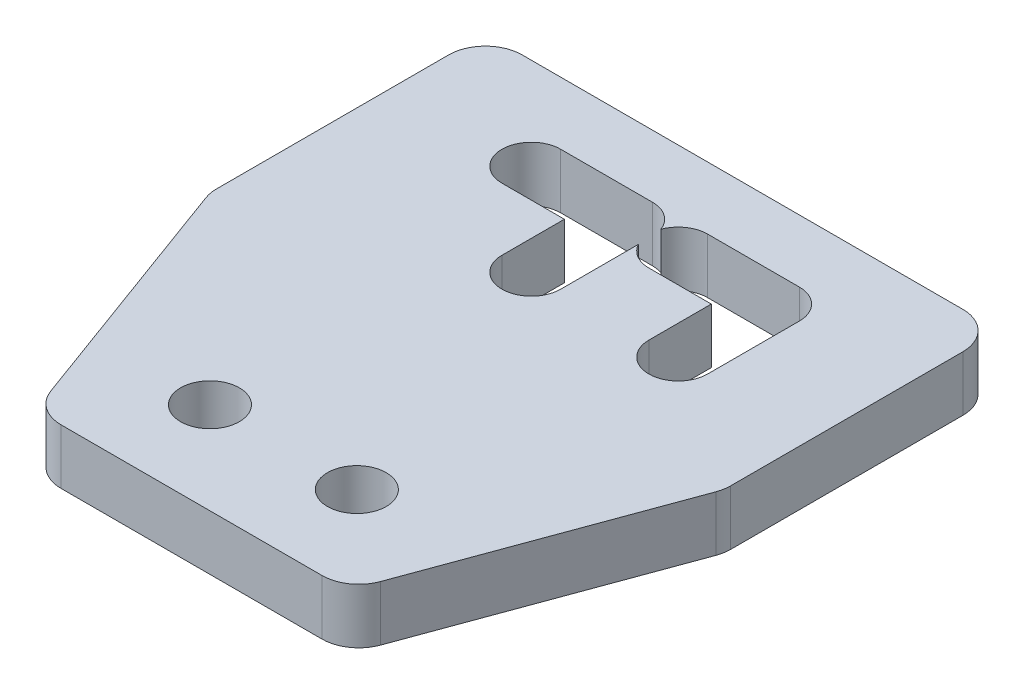
from build123d import *

# Parameters (mm, degrees)
SKETCH1_W           = 28
SKETCH1_H           = 30
BOSS_EXTRUDE1_DEPTH = 3
SKETCH2_R           = 1.6
CUT_EXTRUDE1_DEPTH  = 4
FILLET1_R           = 2


with BuildPart() as part:
    # Sketch1 → Boss-Extrude1 (new body)
    with BuildSketch(Plane(origin=(0, 0, 0), x_dir=(1, 0, 0), z_dir=(0, 1, 0))):
        Rectangle(SKETCH1_W, SKETCH1_H)
        with BuildLine():
            ThreePointArc((1.5, 8.4), (0.687397597, 8.621712173), (0.1, 9.225403331))
            Line((0.1, 9.225403331), (0.1, 5))
            ThreePointArc((0.1, 5), (-1.5, 3.4), (-3.1, 5))
            Line((-3.1, 5), (-3.1, 8.4))
            Line((-3.1, 8.4), (-6.5, 8.4))
            ThreePointArc((-6.5, 8.4), (-8.1, 10), (-6.5, 11.6))
            Line((-6.5, 11.6), (-1.5, 11.6))
            ThreePointArc((-1.5, 11.6), (-0.586447127, 11.313552873), (0, 10.556776436))
            ThreePointArc((0, 10.556776436), (0.586447127, 11.313552873), (1.5, 11.6))
            Line((1.5, 11.6), (6.5, 11.6))
            ThreePointArc((6.5, 11.6), (7.63137085, 11.13137085), (8.1, 10))
            Line((8.1, 10), (8.1, 5))
            ThreePointArc((8.1, 5), (6.5, 3.4), (4.9, 5))
            Line((4.9, 5), (4.9, 8.4))
            Line((4.9, 8.4), (1.5, 8.4))
        make_face(mode=Mode.SUBTRACT)
    extrude(amount=BOSS_EXTRUDE1_DEPTH)

    # Sketch2 → Cut-Extrude1 (cut, through all)
    with BuildSketch(Plane(origin=(0, 3, 0), x_dir=(1, 0, 0), z_dir=(0, 1, 0))):
        with Locations((-4, -10)):
            Circle(SKETCH2_R)
        with Locations((4, -10)):
            Circle(SKETCH2_R)
        Polygon((14, 0), (8.5, -15), (14, -15), align=None)
        Polygon((-8.5, -15), (-14, -15), (-14, 0), align=None)
    extrude(amount=-CUT_EXTRUDE1_DEPTH, mode=Mode.SUBTRACT)

    # Fillet1
    fillet1_edges = [part.edges().sort_by_distance(p)[0] for p in [
        (-14, 1.5, -15),
        (14, 1.5, -15),
        (14, 1.5, 0),
        (8.5, 1.5, 15),
        (-14, 1.5, 0),
        (-8.5, 1.5, 15),
    ]]
    fillet(fillet1_edges, radius=FILLET1_R)


solid = part.part
